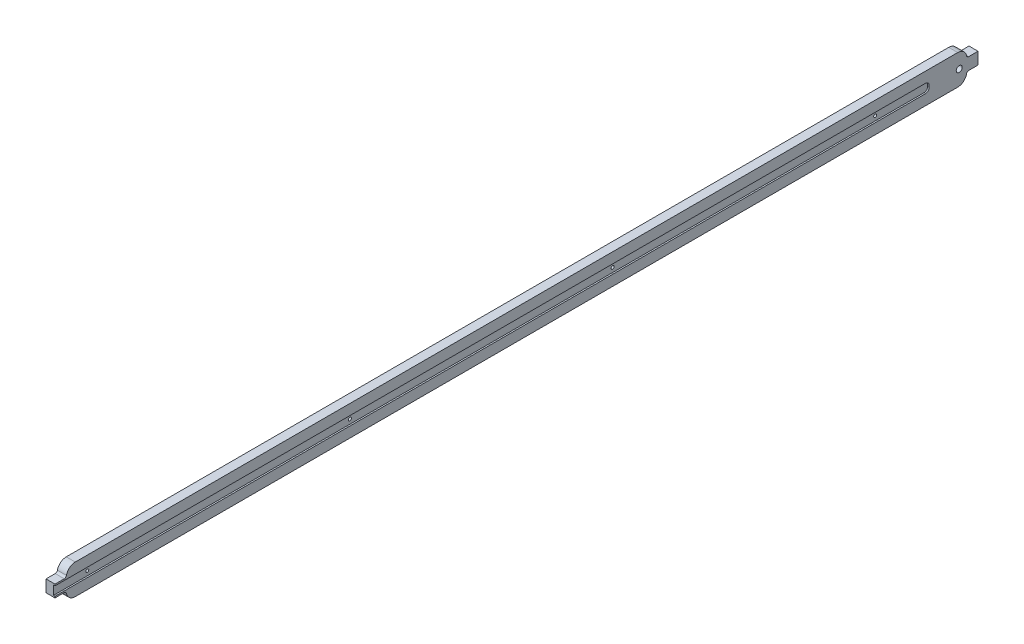
from build123d import *

# Parameters (mm, degrees)
SKETCH1_W                    = 12
SKETCH1_H                    = 40
BOSS_EXTRUDE1_DEPTH          = 600
FILLET1_R                    = 12
SKETCH2_W                    = 1150
SKETCH2_H                    = 12
CUT_EXTRUDE1_DEPTH           = 2
FILLET2_R                    = 5
CUT_EXTRUDE2_REACH           = 14
SKETCH3_R                    = 4
F_4_0_4_DIAMETER_HOLE1_D     = 4
F_4_0_4_DIAMETER_HOLE1_DEPTH = 10
LPATTERN1_COUNT              = 4
LPATTERN1_PITCH              = 350
SKETCH6_W                    = 15
SKETCH6_H                    = 16
BOSS_EXTRUDE2_DEPTH          = 12
CUT_EXTRUDE6_REACH           = 17
SKETCH7_W                    = 2
SKETCH7_H                    = 12
FILLET3_R                    = 3


with BuildPart() as part:
    # Sketch1 → Boss-Extrude1 (new body, symmetric)
    with BuildSketch(Plane.XY):
        Rectangle(SKETCH1_W, SKETCH1_H)
    extrude(amount=BOSS_EXTRUDE1_DEPTH, both=True)

    # Fillet1
    fillet1_edges = [part.edges().sort_by_distance(p)[0] for p in [
        (0, -20, 600),
        (0, -20, -600),
        (0, 20, -600),
        (0, 20, 600),
    ]]
    fillet(fillet1_edges, radius=FILLET1_R)

    # Sketch2 → Cut-Extrude1 (cut)
    with BuildSketch(Plane(origin=(6, 0, 0), x_dir=(0, 0, -1), z_dir=(1, 0, 0))):
        with Locations((-25, 0)):
            Rectangle(SKETCH2_W, SKETCH2_H)
    extrude(amount=-CUT_EXTRUDE1_DEPTH, mode=Mode.SUBTRACT)

    # Fillet2
    fillet2_edges = [part.edges().sort_by_distance(p)[0] for p in [
        (5, 6, -550),
        (5, -6, -550),
    ]]
    fillet(fillet2_edges, radius=FILLET2_R)

    # Sketch3 → Cut-Extrude2 (cut, up to next)
    with BuildSketch(Plane(origin=(6, 0, 0), x_dir=(0, 0, -1), z_dir=(1, 0, 0)), mode=Mode.PRIVATE) as cut_extrude2_sk1:
        with Locations(Location((590, 0, 0), (0, 0, 90))):  # turned: the seam where the file's is
            Circle(SKETCH3_R)
    cut_extrude2_tool1 = extrude(cut_extrude2_sk1.sketch, amount=-CUT_EXTRUDE2_REACH, mode=Mode.PRIVATE) & part.part
    add(cut_extrude2_tool1.solids().sort_by_distance((6, 0, -590))[0], mode=Mode.SUBTRACT)

    # Ø4.0 (4) Diameter Hole1
    with Locations(Plane.ZY.offset(6)):
        with Locations((570, 0)):
            f_4_0_4_diameter_hole1 = Hole(F_4_0_4_DIAMETER_HOLE1_D / 2, depth=F_4_0_4_DIAMETER_HOLE1_DEPTH)

    # LPattern1: Ø4.0 (4) Diameter Hole1 ×4
    with Locations(*[(0, 0, -i * LPATTERN1_PITCH) for i in range(1, LPATTERN1_COUNT)]):
        add(f_4_0_4_diameter_hole1, mode=Mode.SUBTRACT)

    # Sketch6 → Boss-Extrude2 (add)
    with BuildSketch(Plane.ZY.offset(6)):
        with Locations((-607.5, 0)):
            Rectangle(SKETCH6_W, SKETCH6_H)
        with Locations((607.5, 0)):
            Rectangle(SKETCH6_W, SKETCH6_H)
    extrude(amount=-BOSS_EXTRUDE2_DEPTH)

    # Sketch7 → Cut-Extrude6 (cut, up to next)
    with BuildSketch(Plane(origin=(0, 0, 600), x_dir=(-1, 0, 0), z_dir=(0, 0, -1)), mode=Mode.PRIVATE) as cut_extrude6_sk1:
        with Locations((-5, 0)):
            Rectangle(SKETCH7_W, SKETCH7_H)
    cut_extrude6_tool1 = extrude(cut_extrude6_sk1.sketch, amount=-CUT_EXTRUDE6_REACH, mode=Mode.PRIVATE) & part.part
    add(cut_extrude6_tool1.solids().sort_by_distance((5, 0, 600))[0], mode=Mode.SUBTRACT)

    # Fillet3
    fillet3_edges = [part.edges().sort_by_distance(p)[0] for p in [
        (0, -8, 600),
        (0, 8, 600),
        (0, -8, -600),
        (0, 8, -600),
    ]]
    fillet(fillet3_edges, radius=FILLET3_R)


solid = part.part
